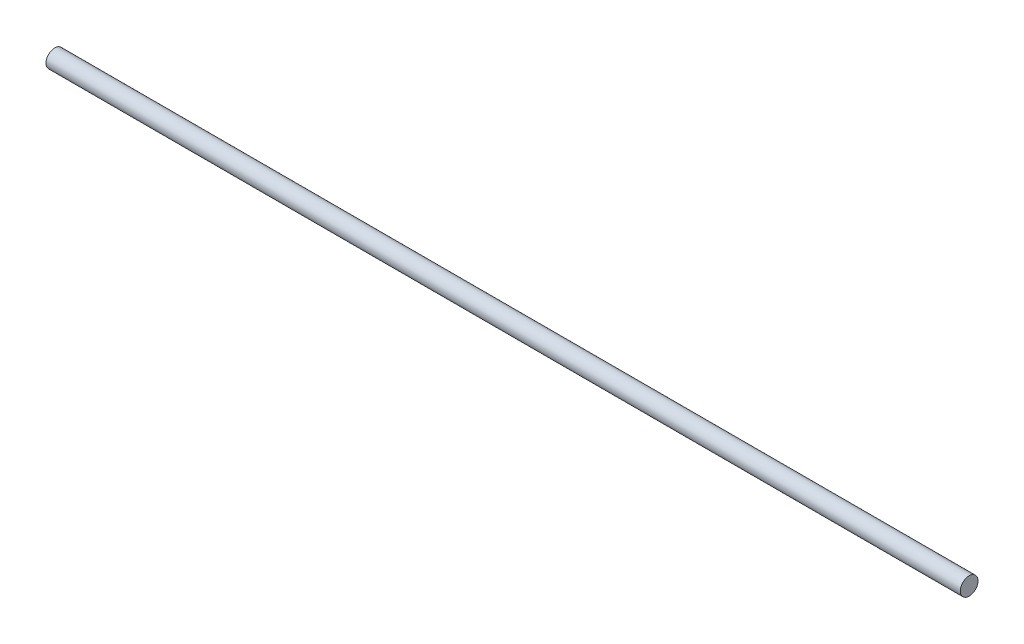
from build123d import *

# Parameters (mm, degrees)
SKETCH1_R           = 10.795
BOSS_EXTRUDE1_DEPTH = 558.8


with BuildPart() as part:
    # Sketch1 → Boss-Extrude1 (new body, symmetric)
    with BuildSketch(Plane(origin=(0, 0, 0), x_dir=(0, 0, -1), z_dir=(1, 0, 0))):
        Circle(SKETCH1_R)
    extrude(amount=BOSS_EXTRUDE1_DEPTH, both=True)


solid = part.part
